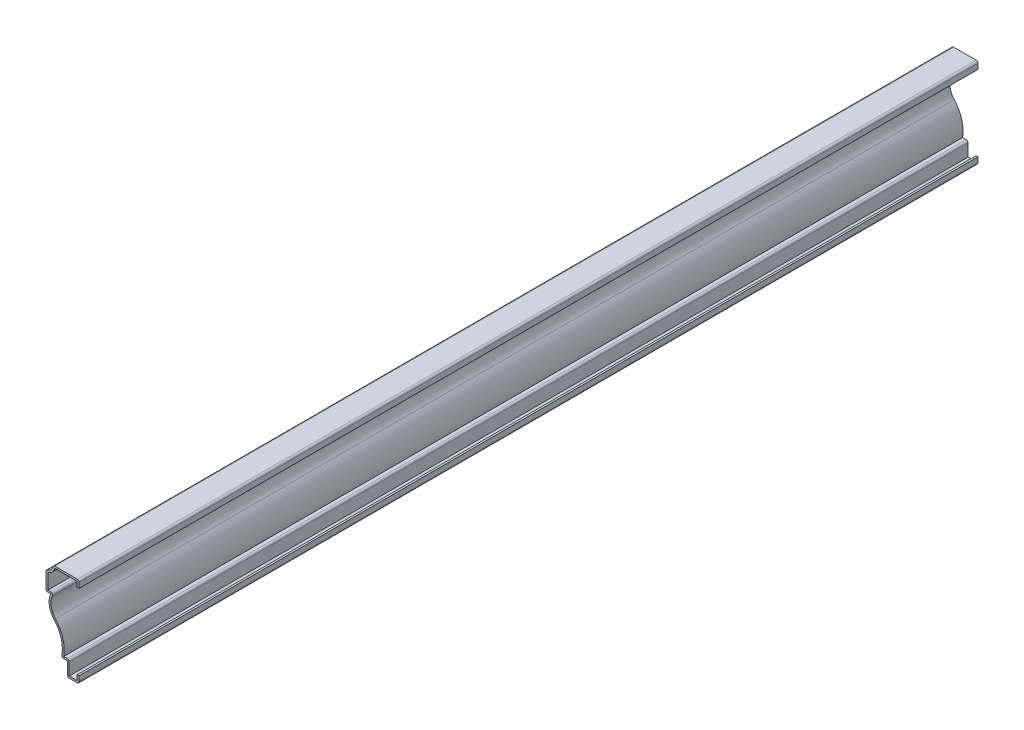
from build123d import *

# Parameters (mm, degrees)
EXTRUDE_THIN1_DEPTH = 603.25
FILLET1_R           = 1.27


with BuildPart() as part:
    # Sketch1 → Extrude-Thin1 (new body)
    with BuildSketch(Plane.XY):
        with BuildLine():
            Line((0, 55.5625), (0, 60.325))
            Line((0, 60.325), (-17.4625, 60.325))
            ThreePointArc((-17.4625, 60.325), (-18.857403955, 56.957403955), (-22.225, 55.5625))
            Line((-22.225, 55.5625), (-22.225, 42.795329036))
            Line((-22.225, 42.795329036), (-19.05, 42.795329036))
            ThreePointArc((-19.05, 42.795329036), (-19.983849695, 35.617826147), (-16.845026643, 29.095831604))
            ThreePointArc((-16.845026643, 29.095831604), (-11.927389151, 19.928241149), (-11.90625, 9.525))
            Line((-11.90625, 9.525), (-7.9375, 9.525))
            Line((-7.9375, 9.525), (-7.9375, 0))
            Line((-7.9375, 0), (0, 0))
            Line((0, 0), (0, 4.7625))
            Line((0, 4.7625), (-1.27, 4.7625))
            Line((-1.27, 4.7625), (-1.27, 1.27))
            Line((-1.27, 1.27), (-6.6675, 1.27))
            Line((-6.6675, 1.27), (-6.6675, 10.795))
            Line((-6.6675, 10.795), (-10.341607608, 10.795))
            ThreePointArc((-10.341607608, 10.795), (-10.90685332, 21.016186768), (-15.905046277, 29.949843847))
            ThreePointArc((-15.905046277, 29.949843847), (-18.847187578, 36.835889429), (-16.895515947, 44.065329036))
            Line((-16.895515947, 44.065329036), (-20.955, 44.065329036))
            Line((-20.955, 44.065329036), (-20.955, 54.42769924))
            ThreePointArc((-20.955, 54.42769924), (-17.959378342, 56.059378342), (-16.32769924, 59.055))
            Line((-16.32769924, 59.055), (-1.27, 59.055))
            Line((-1.27, 59.055), (-1.27, 55.5625))
            Line((-1.27, 55.5625), (0, 55.5625))
        make_face()
    extrude(amount=-EXTRUDE_THIN1_DEPTH)

    # Fillet1
    fillet1_edges = [part.edges().sort_by_distance(p)[0] for p in [
        (0, 0, -301.625),
        (-7.9375, 0, -301.625),
        (-11.90625, 9.525, -301.625),
        (-22.225, 42.795329036, -301.625),
        (-22.225, 55.5625, -301.625),
        (-17.4625, 60.325, -301.625),
        (0, 60.325, -301.625),
        (-16.895515947, 44.065329036, -301.625),
        (-6.6675, 10.795, -301.625),
    ]]
    fillet(fillet1_edges, radius=FILLET1_R)


solid = part.part
